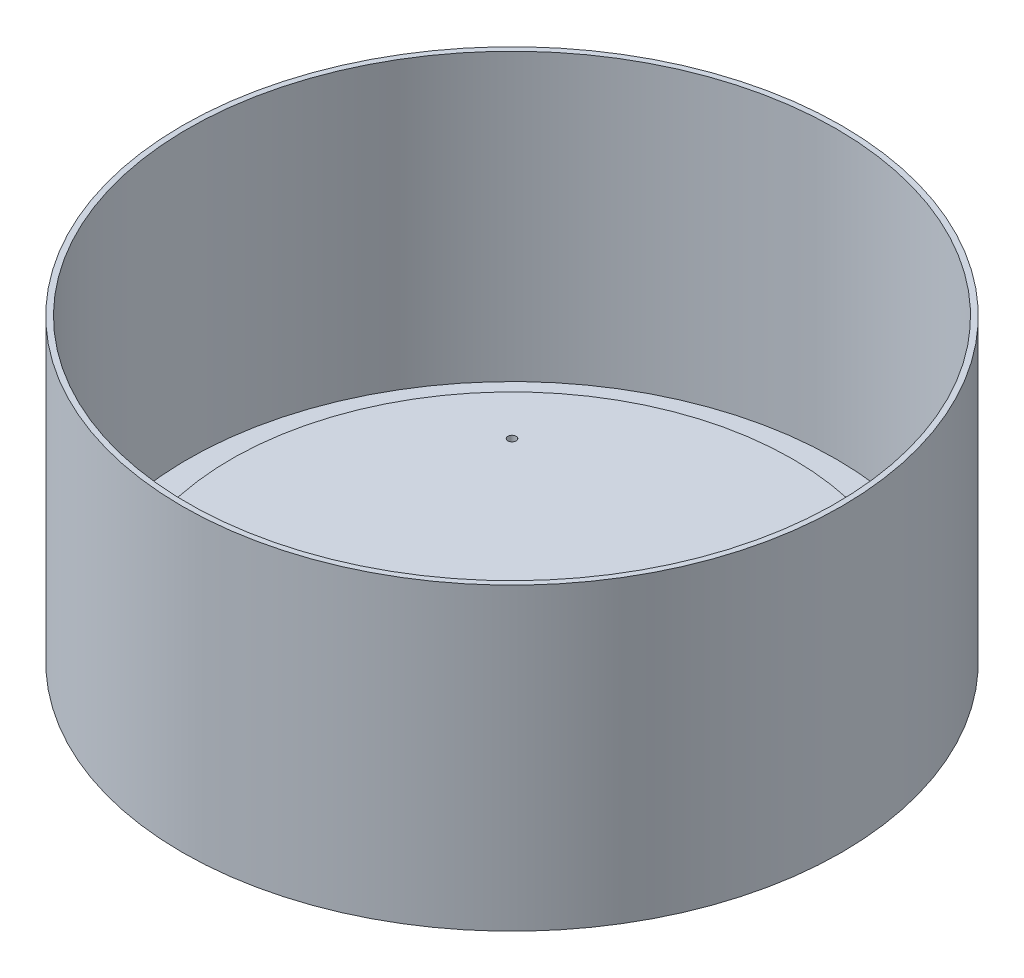
from build123d import *

# Parameters (mm, degrees)
SKETCH_1_W          = 103
SKETCH_1_H          = 3.03
SKETCH_2_R          = 1.5
CUT_EXTRUDE_1_DEPTH = 14.03


with BuildPart() as part:
    # Эскиз1 → Повернуть1 (revolve)
    with BuildSketch(Plane.XY):
        Polygon((0, 0), (0, 10), (103, 10), (107, 5), (119, 5), (119, 0), align=None)
        with Locations((51.5, 11.515)):
            Rectangle(SKETCH_1_W, SKETCH_1_H)
        Polygon((119, 5), (119, 0), (121, 0), (121, 110), (119, 110), align=None)
    revolve(axis=Axis((0, 0, 0), (0, 1, 0)))

    # Эскиз2 → Вырез-Вытянуть1 (cut, through all)
    with BuildSketch(Plane(origin=(0, 13.03, 0), x_dir=(1, 0, 0), z_dir=(0, 1, 0))):
        with Locations((-58, 58)):
            Circle(SKETCH_2_R)
        with Locations((58, 58)):
            Circle(SKETCH_2_R)
        with Locations((58, -58)):
            Circle(SKETCH_2_R)
        with Locations((-58, -58)):
            Circle(SKETCH_2_R)
    extrude(amount=-CUT_EXTRUDE_1_DEPTH, mode=Mode.SUBTRACT)


solid = part.part
